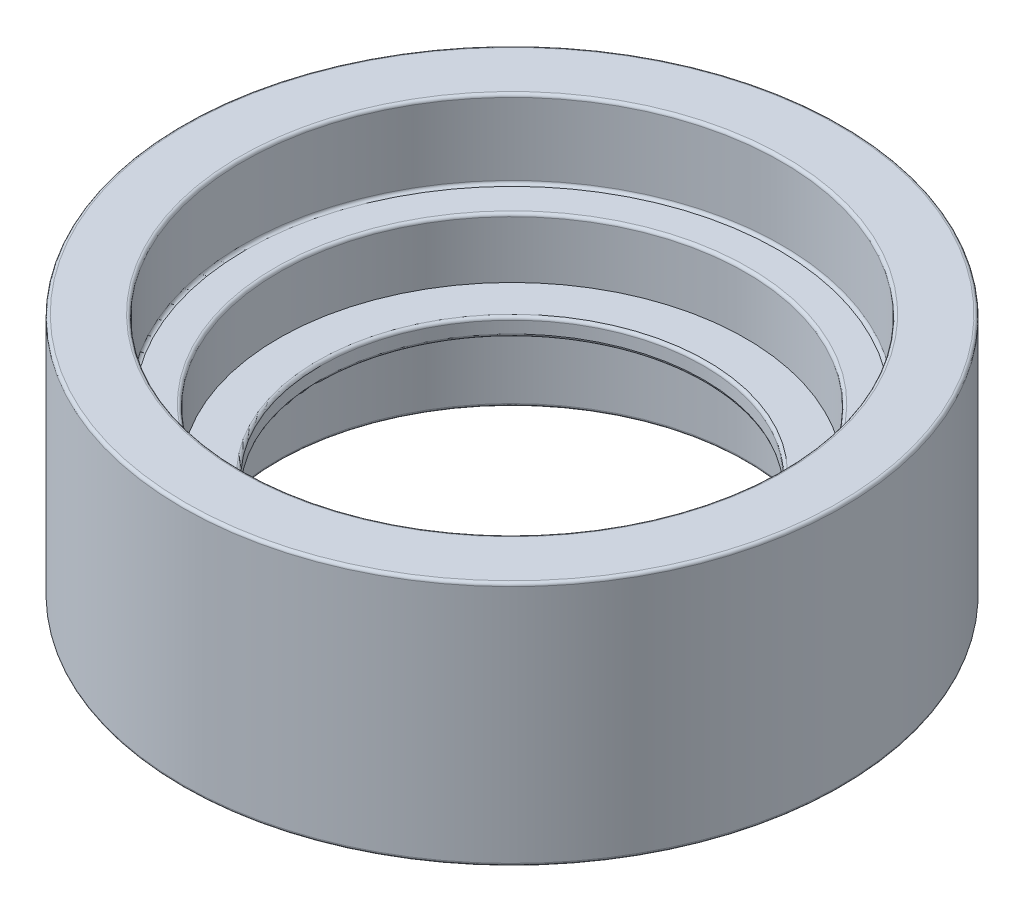
from build123d import *

# Parameters (mm, degrees)
BOSS_EXTRUDE4_DEPTH      = 1.5
BOSS_EXTRUDE4_DEPTH_BACK = 1.5
SKETCH3_R                = 39
SKETCH3_R_2              = 32
BOSS_EXTRUDE5_DEPTH      = 11.5
BOSS_EXTRUDE5_DEPTH_BACK = 16.5
SKETCH3_3_R              = 45
SKETCH3_3_R_2            = 39
BOSS_EXTRUDE6_DEPTH      = 24.5
BOSS_EXTRUDE6_DEPTH_BACK = 16.5
SKETCH3_4_R              = 55
SKETCH3_4_R_2            = 45
SKETCH4_R                = 2
CUT_EXTRUDE1_DEPTH       = 10
FILLET1_R                = 0.5


with BuildPart() as part:
    # Sketch3 → Boss-Extrude4 (new, two sides: drawn at the far end of the back side and taken through both)
    with BuildSketch(Plane(origin=(0, 0, 0), x_dir=(1, 0, 0), z_dir=(0, 1, 0)).offset(-BOSS_EXTRUDE4_DEPTH_BACK)):
        Circle(SKETCH3_R)
        Circle(SKETCH3_R_2, mode=Mode.SUBTRACT)
    extrude(amount=BOSS_EXTRUDE4_DEPTH + BOSS_EXTRUDE4_DEPTH_BACK)

    # Sketch3_3 → Boss-Extrude5 (add, two sides: drawn at the far end of the back side and taken through both)
    with BuildSketch(Plane(origin=(0, 0, 0), x_dir=(1, 0, 0), z_dir=(0, 1, 0)).offset(-BOSS_EXTRUDE5_DEPTH_BACK)):
        Circle(SKETCH3_3_R)
        Circle(SKETCH3_3_R_2, mode=Mode.SUBTRACT)
    extrude(amount=BOSS_EXTRUDE5_DEPTH + BOSS_EXTRUDE5_DEPTH_BACK)

    # Sketch3_4 → Boss-Extrude6 (add, two sides: drawn at the far end of the back side and taken through both)
    with BuildSketch(Plane(origin=(0, 0, 0), x_dir=(1, 0, 0), z_dir=(0, 1, 0)).offset(-BOSS_EXTRUDE6_DEPTH_BACK)):
        Circle(SKETCH3_4_R)
        Circle(SKETCH3_4_R_2, mode=Mode.SUBTRACT)
    extrude(amount=BOSS_EXTRUDE6_DEPTH + BOSS_EXTRUDE6_DEPTH_BACK)

    # Sketch4 → Cut-Extrude1 (cut)
    with BuildSketch(Plane.XZ.offset(16.5)):
        with Locations((0, 47)):
            Circle(SKETCH4_R)
        with Locations((33.234018716, 33.234018716)):
            Circle(SKETCH4_R)
        with Locations((47, 0)):
            Circle(SKETCH4_R)
        with Locations((33.234018716, -33.234018716)):
            Circle(SKETCH4_R)
        with Locations((0, -47)):
            Circle(SKETCH4_R)
        with Locations((-33.234018716, -33.234018716)):
            Circle(SKETCH4_R)
        with Locations((-47, 0)):
            Circle(SKETCH4_R)
        with Locations((-33.234018716, 33.234018716)):
            Circle(SKETCH4_R)
    extrude(amount=-CUT_EXTRUDE1_DEPTH, mode=Mode.SUBTRACT)

    # Fillet1
    fillet1_edges = [part.edges().sort_by_distance(p)[0] for p in [
        (-55, -16.5, 0),
        (-39, -16.5, 0),
        (-35.234018716, -16.5, 33.234018716),
        (-49, -16.5, 0),
        (-35.234018716, -16.5, -33.234018716),
        (-2, -16.5, -47),
        (31.234018716, -16.5, -33.234018716),
        (45, -16.5, 0),
        (31.234018716, -16.5, 33.234018716),
        (-2, -16.5, 47),
        (-45, 11.5, 0),
        (-39, 11.5, 0),
        (-55, 24.5, 0),
        (-45, 24.5, 0),
        (-32, -1.5, 0),
        (-32, 1.5, 0),
    ]]
    fillet(fillet1_edges, radius=FILLET1_R)


solid = part.part
